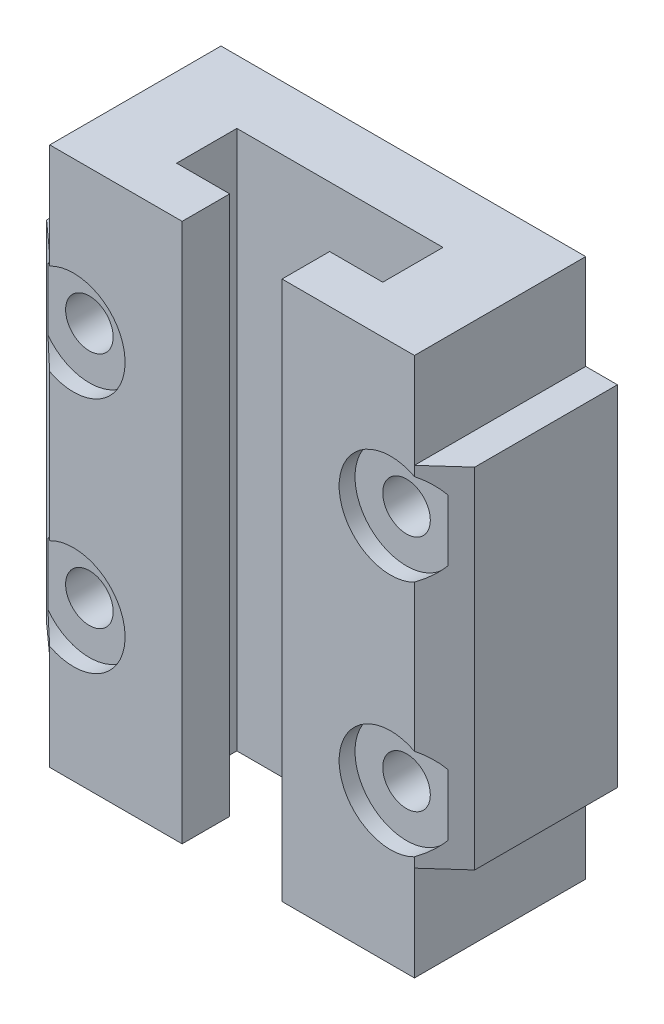
from build123d import *

# Parameters (mm, degrees)
SKETCH_1_W          = 23
SKETCH_1_H          = 10.8
EXTRUDE_1_DEPTH     = 34
CUT_EXTRUDE_1_DEPTH = 35
SKETCH_3_W          = 7
SKETCH_3_H          = 22
EXTRUDE_2_DEPTH     = 9
EXTRUDE_3_DEPTH     = 22
SKETCH_7_R          = 3.25
CUT_EXTRUDE_7_DEPTH = 1
CUT_EXTRUDE_8_REACH = 11.8
SKETCH_8_R          = 1.5


with BuildPart() as part:
    # 草图1 → 凸台-拉伸1 (new body)
    with BuildSketch(Plane(origin=(0, 0, 0), x_dir=(1, 0, 0), z_dir=(0, 1, 0))):
        Rectangle(SKETCH_1_W, SKETCH_1_H)
    extrude(amount=EXTRUDE_1_DEPTH)

    # 草图2 → 切除-拉伸1 (cut, through all)
    with BuildSketch(Plane(origin=(0, 34, 0), x_dir=(1, 0, 0), z_dir=(0, 1, 0))):
        Polygon((-6.5, 1.4), (6.5, 1.4), (6.5, -2.4), (3.15, -2.4), (3.15, -5.4), (-3.15, -5.4), (-3.15, -2.4), (-6.5, -2.4), align=None)
    extrude(amount=-CUT_EXTRUDE_1_DEPTH, mode=Mode.SUBTRACT)

    # 草图3 → 凸台-拉伸2 (add)
    with BuildSketch(Plane(origin=(0, 0, -5.4), x_dir=(-1, 0, 0), z_dir=(0, 0, -1))):
        with Locations((-10, 17)):
            Rectangle(SKETCH_3_W, SKETCH_3_H)
        with Locations((10, 17)):
            Rectangle(SKETCH_3_W, SKETCH_3_H)
    extrude(amount=-EXTRUDE_2_DEPTH)

    # 草图5 → 凸台-拉伸3 (add)
    with BuildSketch(Plane.XZ.offset(-6)):
        Polygon((11.5, 5.4), (11.5, 3.6), (13.5, 3.6), align=None)
        Polygon((-13.5, 3.6), (-11.5, 5.4), (-11.5, 3.6), align=None)
    extrude(amount=-EXTRUDE_3_DEPTH)

    # 草图7 → 切除-拉伸7 (cut)
    with BuildSketch(Plane.XY.offset(5.4)):
        with Locations((-10, 24.5)):
            Circle(SKETCH_7_R)
        with Locations((-10, 9.5)):
            Circle(SKETCH_7_R)
        with Locations((10, 9.5)):
            Circle(SKETCH_7_R)
        with Locations((10, 24.5)):
            Circle(SKETCH_7_R)
    extrude(amount=-CUT_EXTRUDE_7_DEPTH, mode=Mode.SUBTRACT)

    # 草图8 → 切除-拉伸8 (cut, up to next)
    with BuildSketch(Plane.XY.offset(4.4), mode=Mode.PRIVATE) as cut_extrude_8_sk1:
        with Locations((-10, 24.5)):
            Circle(SKETCH_8_R)
    cut_extrude_8_tool1 = extrude(cut_extrude_8_sk1.sketch, amount=-CUT_EXTRUDE_8_REACH, mode=Mode.PRIVATE) & part.part
    add(cut_extrude_8_tool1.solids().sort_by_distance((-10, 24.5, 4.4))[0], mode=Mode.SUBTRACT)
    # 草图8 → 切除-拉伸8 (cut, up to next)
    with BuildSketch(Plane.XY.offset(4.4), mode=Mode.PRIVATE) as cut_extrude_8_sk2:
        with Locations((10, 24.5)):
            Circle(SKETCH_8_R)
    cut_extrude_8_tool2 = extrude(cut_extrude_8_sk2.sketch, amount=-CUT_EXTRUDE_8_REACH, mode=Mode.PRIVATE) & part.part
    add(cut_extrude_8_tool2.solids().sort_by_distance((10, 24.5, 4.4))[0], mode=Mode.SUBTRACT)
    # 草图8 → 切除-拉伸8 (cut, up to next)
    with BuildSketch(Plane.XY.offset(4.4), mode=Mode.PRIVATE) as cut_extrude_8_sk3:
        with Locations((-10, 9.5)):
            Circle(SKETCH_8_R)
    cut_extrude_8_tool3 = extrude(cut_extrude_8_sk3.sketch, amount=-CUT_EXTRUDE_8_REACH, mode=Mode.PRIVATE) & part.part
    add(cut_extrude_8_tool3.solids().sort_by_distance((-10, 9.5, 4.4))[0], mode=Mode.SUBTRACT)
    # 草图8 → 切除-拉伸8 (cut, up to next)
    with BuildSketch(Plane.XY.offset(4.4), mode=Mode.PRIVATE) as cut_extrude_8_sk4:
        with Locations((10, 9.5)):
            Circle(SKETCH_8_R)
    cut_extrude_8_tool4 = extrude(cut_extrude_8_sk4.sketch, amount=-CUT_EXTRUDE_8_REACH, mode=Mode.PRIVATE) & part.part
    add(cut_extrude_8_tool4.solids().sort_by_distance((10, 9.5, 4.4))[0], mode=Mode.SUBTRACT)


solid = part.part
